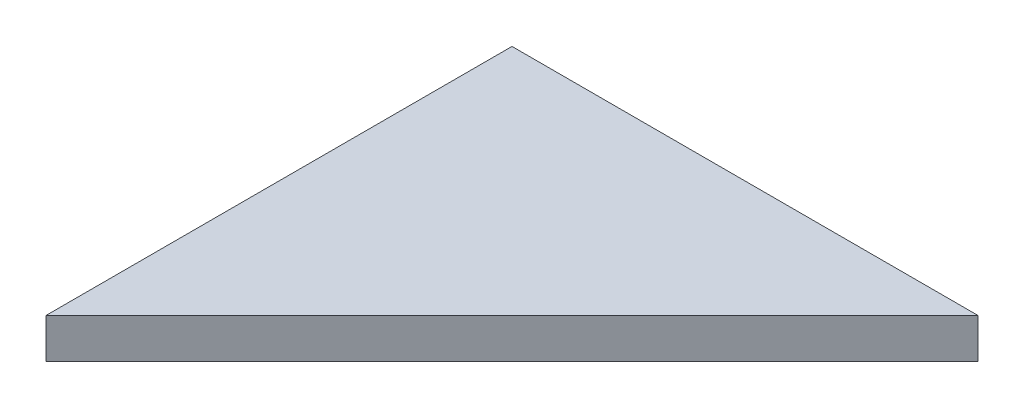
from build123d import *

# Parameters (mm, degrees)
BOSS_EXTRUDE1_DEPTH = 6


with BuildPart() as part:
    # Sketch1 → Boss-Extrude1 (new body)
    with BuildSketch(Plane(origin=(0, 0, 0), x_dir=(1, 0, 0), z_dir=(0, 1, 0))):
        Polygon((0, 0), (70, 0), (0, -70), align=None)
    extrude(amount=BOSS_EXTRUDE1_DEPTH)


solid = part.part
